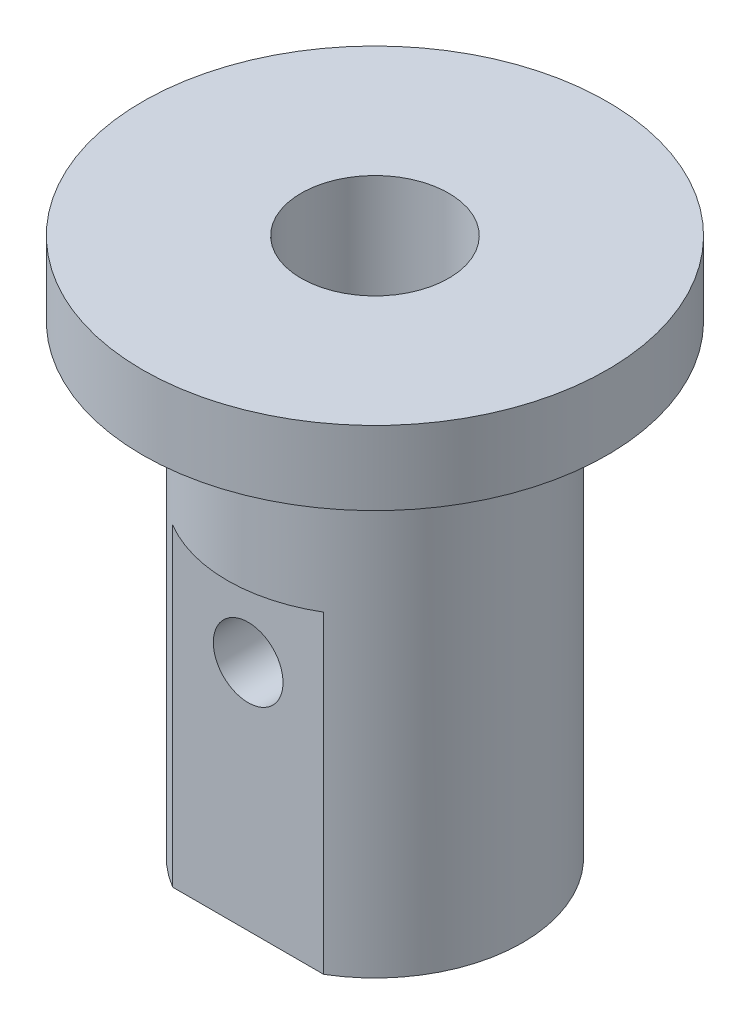
from build123d import *

# Parameters (mm, degrees)
SKETCH1_R               = 6.35
SKETCH1_R_2             = 3.175
BOSS_EXTRUDE1_DEPTH     = 20
SKETCH2_R               = 10
SKETCH2_R_2             = 3.175
BOSS_EXTRUDE2_DEPTH     = 3.175
CUT_EXTRUDE1_DEPTH      = 10
CUT_EXTRUDE1_DEPTH_BACK = 28.14922881
SKETCH3_R               = 1.5
SKETCH4_W               = 6.5
SKETCH4_H               = 0.894727321
CUT_EXTRUDE2_DEPTH      = 13.5


with BuildPart() as part:
    # Sketch1 → Boss-Extrude1 (new body)
    with BuildSketch(Plane(origin=(0, 0, 0), x_dir=(1, 0, 0), z_dir=(0, 1, 0))):
        Circle(SKETCH1_R)
        Circle(SKETCH1_R_2, mode=Mode.SUBTRACT)
    extrude(amount=BOSS_EXTRUDE1_DEPTH)

    # Sketch2 → Boss-Extrude2 (add)
    with BuildSketch(Plane(origin=(0, 20, 0), x_dir=(1, 0, 0), z_dir=(0, 1, 0))):
        Circle(SKETCH2_R)
        Circle(SKETCH2_R_2, mode=Mode.SUBTRACT)
    extrude(amount=BOSS_EXTRUDE2_DEPTH)

    # Sketch3 → Cut-Extrude1 (cut, two sides: drawn at the far end of the back side and taken through both)
    with BuildSketch(Plane.XY.offset(-CUT_EXTRUDE1_DEPTH_BACK)):
        with Locations((0, 10)):
            Circle(SKETCH3_R)
    extrude(amount=CUT_EXTRUDE1_DEPTH + CUT_EXTRUDE1_DEPTH_BACK, mode=Mode.SUBTRACT)

    # Sketch4 → Cut-Extrude2 (cut)
    with BuildSketch(Plane.XZ):
        with Locations((0, -5.90263634)):
            Rectangle(SKETCH4_W, SKETCH4_H)
        with Locations((0, 5.90263634)):
            Rectangle(SKETCH4_W, SKETCH4_H)
    extrude(amount=-CUT_EXTRUDE2_DEPTH, mode=Mode.SUBTRACT)


solid = part.part
